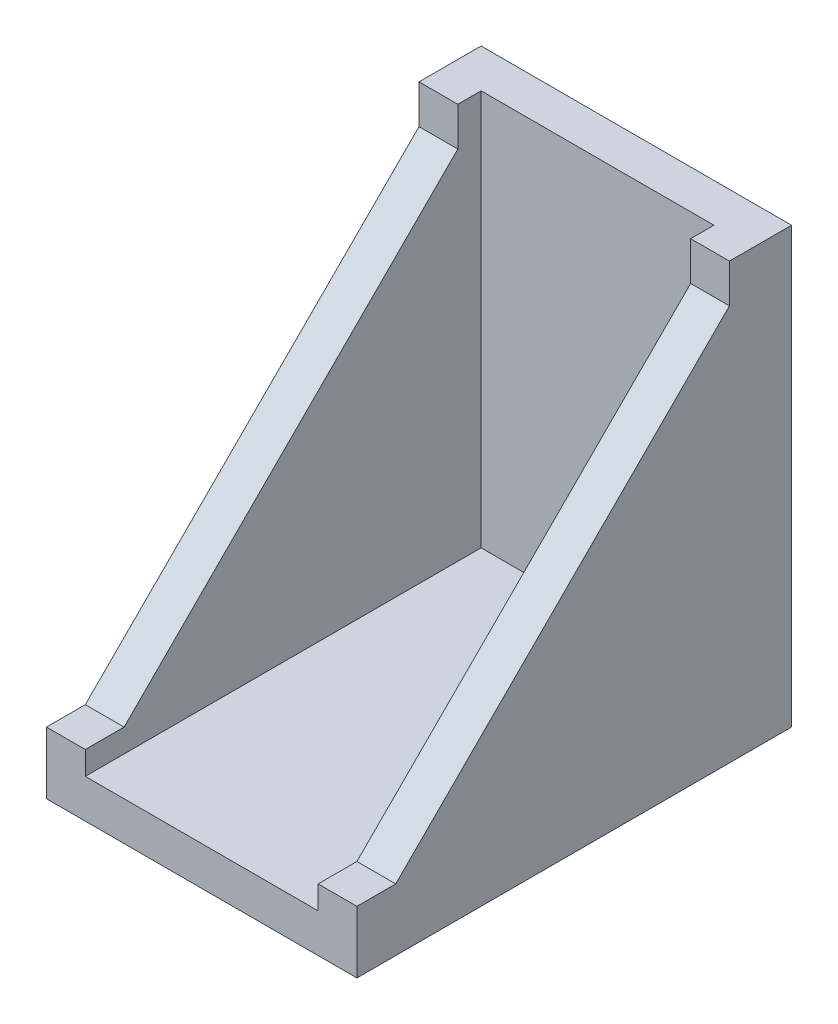
from build123d import *

# Parameters (mm, degrees)
SKETCH1_W                      = 20
SKETCH1_H                      = 28
BOSS_EXTRUDE1_DEPTH            = 28
SKETCH2_W                      = 15
SKETCH2_H                      = 25.5
CUT_EXTRUDE1_DEPTH             = 25.5
CUT_EXTRUDE2_REACH             = 12
CUT_EXTRUDE2_DIRECTION_2_REACH = 12


with BuildPart() as part:
    # Sketch1 → Boss-Extrude1 (new body)
    with BuildSketch(Plane(origin=(0, 0, 0), x_dir=(1, 0, 0), z_dir=(0, 1, 0))):
        with Locations((10, -14)):
            Rectangle(SKETCH1_W, SKETCH1_H)
    extrude(amount=BOSS_EXTRUDE1_DEPTH)

    # Sketch2 → Cut-Extrude1 (cut)
    with BuildSketch(Plane(origin=(0, 28, 0), x_dir=(1, 0, 0), z_dir=(0, 1, 0))):
        with Locations((10, -15.25)):
            Rectangle(SKETCH2_W, SKETCH2_H)
    extrude(amount=-CUT_EXTRUDE1_DEPTH, mode=Mode.SUBTRACT)

    # Sketch3 → Cut-Extrude2 (cut, up to next)
    with BuildSketch(Plane.ZY.offset(-10), mode=Mode.PRIVATE) as cut_extrude2_sk1:
        Polygon((4, 28), (4, 25.5), (25.5, 4), (28, 4), (28, 28), align=None)
    cut_extrude2_tool1 = extrude(cut_extrude2_sk1.sketch, amount=-CUT_EXTRUDE2_REACH, mode=Mode.PRIVATE) & part.part
    add(cut_extrude2_tool1.solids().sort_by_distance((10, 19.239157, 19.239157))[0], mode=Mode.SUBTRACT)

    # Sketch3 → Cut-Extrude2 direction 2 (cut, up to next)
    with BuildSketch(Plane.ZY.offset(-10), mode=Mode.PRIVATE) as cut_extrude2_direction_2_sk1:
        Polygon((4, 28), (4, 25.5), (25.5, 4), (28, 4), (28, 28), align=None)
    cut_extrude2_direction_2_tool1 = extrude(cut_extrude2_direction_2_sk1.sketch, amount=CUT_EXTRUDE2_DIRECTION_2_REACH, mode=Mode.PRIVATE) & part.part
    add(cut_extrude2_direction_2_tool1.solids().sort_by_distance((10, 19.239157, 19.239157))[0], mode=Mode.SUBTRACT)


solid = part.part
